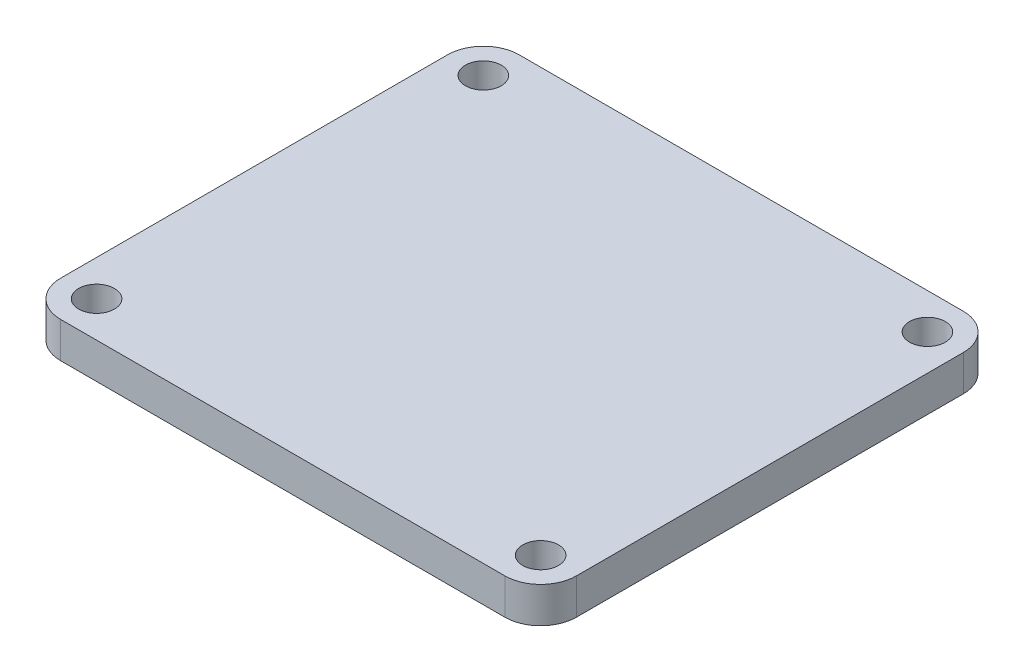
from build123d import *

# Parameters (mm, degrees)
SKETCH1_W           = 72
SKETCH1_H           = 64
SKETCH1_R           = 2.5
BOSS_EXTRUDE1_DEPTH = 5
FILLET1_R           = 5


with BuildPart() as part:
    # Sketch1 → Boss-Extrude1 (new body)
    with BuildSketch(Plane(origin=(0, 0, 0), x_dir=(1, 0, 0), z_dir=(0, 1, 0))):
        with Locations((3.915789474, -14.442105263)):
            Rectangle(SKETCH1_W, SKETCH1_H)
        with Locations((34.915789474, 12.557894737)):
            Circle(SKETCH1_R, mode=Mode.SUBTRACT)
        with Locations((-27.084210526, 12.557894737)):
            Circle(SKETCH1_R, mode=Mode.SUBTRACT)
        with Locations((34.915789474, -41.442105263)):
            Circle(SKETCH1_R, mode=Mode.SUBTRACT)
        with Locations((-27.084210526, -41.442105263)):
            Circle(SKETCH1_R, mode=Mode.SUBTRACT)
    extrude(amount=BOSS_EXTRUDE1_DEPTH)

    # Fillet1
    fillet1_edges = [part.edges().sort_by_distance(p)[0] for p in [
        (-32.084210526, 2.5, -17.557894737),
        (39.915789474, 2.5, -17.557894737),
        (39.915789474, 2.5, 46.442105263),
        (-32.084210526, 2.5, 46.442105263),
    ]]
    fillet(fillet1_edges, radius=FILLET1_R)


solid = part.part
